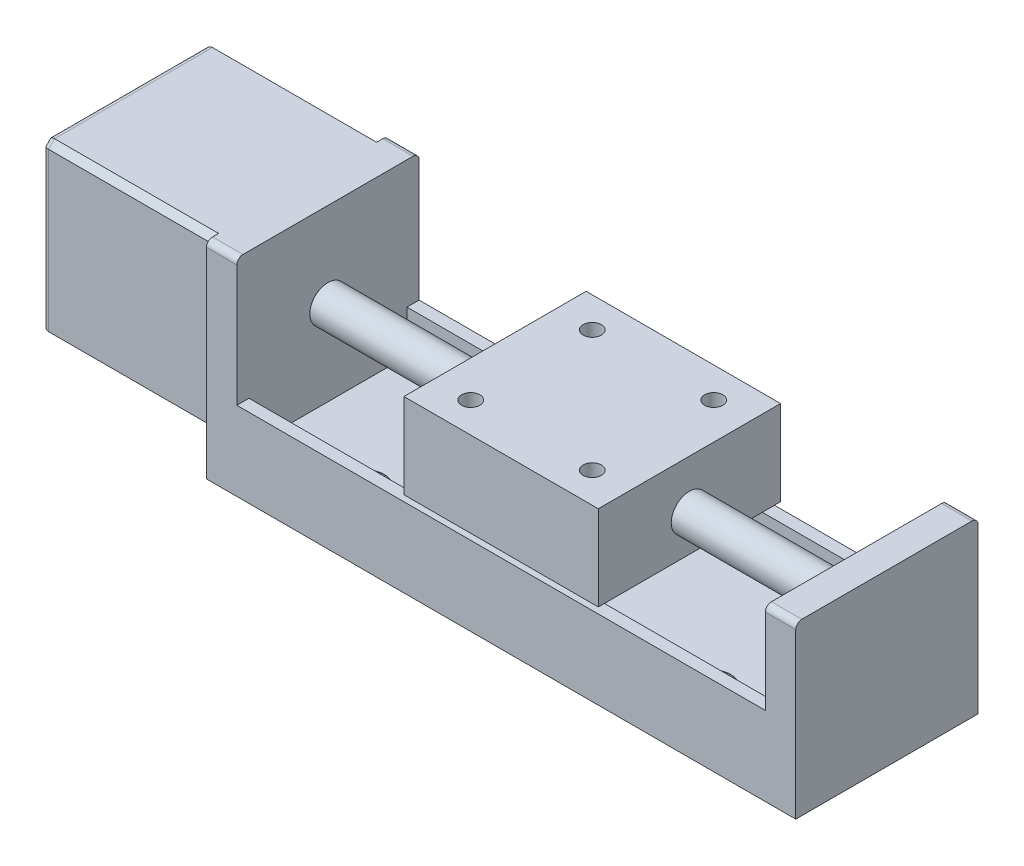
from build123d import *

# Parameters (mm, degrees)
BOSS_EXTRUDE1_DEPTH                          = 15
SKETCH2_W                                    = 87
SKETCH2_H                                    = 26
CUT_EXTRUDE1_DEPTH                           = 7
SKETCH3_R                                    = 3
BOSS_EXTRUDE2_DEPTH                          = 92
CUT_EXTRUDE2_DEPTH                           = 35
CHAMFER1_SIZE                                = 1
FILLET1_R                                    = 1
FILLET2_R                                    = 1
CBORE_FOR_M3_HEX_SOCKET_HEAD_CAP_SCR_2_COUNT = 2
CBORE_FOR_M3_HEX_SOCKET_HEAD_CAP_SCR_2_PITCH = 17
CBORE_FOR_M3_HEX_SOCKET_HEAD_CAP_SCR_3_COUNT = 2
CBORE_FOR_M3_HEX_SOCKET_HEAD_CAP_SCR_3_PITCH = 57
CBORE_FOR_M3_HEX_SOCKET_HEAD_CAP_SCR_4_COUNT = 2
CBORE_FOR_M3_HEX_SOCKET_HEAD_CAP_SCR_4_PITCH = 59.481089432
SKETCH7_W                                    = 32
SKETCH7_H                                    = 30
BOSS_EXTRUDE3_DEPTH                          = 14
SKETCH10_W                                   = 1.5
SKETCH10_H                                   = 6
HOLE1_AT_2_COUNT                             = 2
HOLE1_AT_2_PITCH                             = 20
HOLE1_AT_3_COUNT                             = 2
HOLE1_AT_3_PITCH                             = 28.284271247
HOLE1_AT_4_COUNT                             = 2
HOLE1_AT_4_PITCH                             = 20


with BuildPart() as part:
    # Sketch1 → Boss-Extrude1 (new body, symmetric)
    with BuildSketch(Plane.XY):
        Polygon((-78.5, 34), (-78.5, 6), (-48.5, 6), (-48.5, 0), (48.5, 0), (48.5, 28), (43.5, 28), (43.5, 13), (-43.5, 13), (-43.5, 34), align=None)
    extrude(amount=BOSS_EXTRUDE1_DEPTH, both=True)

    # Sketch2 → Cut-Extrude1 (cut)
    with BuildSketch(Plane(origin=(0, 13, 0), x_dir=(1, 0, 0), z_dir=(0, 1, 0))):
        Rectangle(SKETCH2_W, SKETCH2_H)
    extrude(amount=-CUT_EXTRUDE1_DEPTH, mode=Mode.SUBTRACT)

    # Sketch3 → Boss-Extrude2 (add)
    with BuildSketch(Plane(origin=(48.5, 0, 0), x_dir=(0, 0, -1), z_dir=(1, 0, 0))):
        with Locations((0, 20)):
            Circle(SKETCH3_R)
    extrude(amount=-BOSS_EXTRUDE2_DEPTH)

    # Sketch4 → Cut-Extrude2 (cut, through all)
    with BuildSketch(Plane(origin=(0, 34, 0), x_dir=(1, 0, 0), z_dir=(0, 1, 0))):
        Polygon((-48.5, -15), (-48.5, -14), (-76.5, -14), (-76.5, 14), (-48.5, 14), (-48.5, 15), (-78.5, 15), (-78.5, -15), align=None)
    extrude(amount=-CUT_EXTRUDE2_DEPTH, mode=Mode.SUBTRACT)

    # Chamfer1
    chamfer1_edges = [part.edges().sort_by_distance(p)[0] for p in [
        (-62.5, 6, -14),
        (-62.5, 6, 14),
        (-62.5, 34, 14),
        (-62.5, 34, -14),
    ]]
    chamfer(chamfer1_edges, length=CHAMFER1_SIZE)

    # Fillet1
    fillet1_edges = [part.edges().sort_by_distance(p)[0] for p in [
        (-76.5, 34, 0),
        (-76.5, 20, -14),
        (-76.5, 33.5, 13.5),
        (-76.5, 33.5, -13.5),
        (-76.5, 6.5, -13.5),
        (-76.5, 6.5, 13.5),
        (-76.5, 6, 0),
        (-76.5, 20, 14),
    ]]
    fillet(fillet1_edges, radius=FILLET1_R)

    # Fillet2
    fillet2_edges = [part.edges().sort_by_distance(p)[0] for p in [
        (-46, 34, -15),
        (46, 28, -15),
        (46, 28, 15),
        (-46, 34, 15),
    ]]
    fillet(fillet2_edges, radius=FILLET2_R)

    # Sketch6 → CBORE for M3 Hex Socket Head Cap Screw1 (revolve, cut)
    with BuildSketch(Plane(origin=(-28.5, 6, -8.006829487), x_dir=(0, 0, 1), z_dir=(1, 0, 0))):
        Polygon((0, 0), (0, 6), (1.7, 6), (1.7, 3.4), (3.25, 3.4), (3.25, 0.025), (3.275, 0), align=None)
    cbore_for_m3_hex_socket_head_cap_screw1 = revolve(axis=Axis((-28.5, 12.35, -8.006829487), (0, -1, 0)), mode=Mode.SUBTRACT)

    # CBORE for M3 Hex Socket Head Cap Scr 2: CBORE for M3 Hex Socket Head Cap Screw1 ×2
    with Locations(*[(0, 0, i * CBORE_FOR_M3_HEX_SOCKET_HEAD_CAP_SCR_2_PITCH) for i in range(1, CBORE_FOR_M3_HEX_SOCKET_HEAD_CAP_SCR_2_COUNT)]):
        add(cbore_for_m3_hex_socket_head_cap_screw1, mode=Mode.SUBTRACT)

    # CBORE for M3 Hex Socket Head Cap Scr 3: CBORE for M3 Hex Socket Head Cap Screw1 ×2
    with Locations(*[(i * CBORE_FOR_M3_HEX_SOCKET_HEAD_CAP_SCR_3_PITCH, 0, 0) for i in range(1, CBORE_FOR_M3_HEX_SOCKET_HEAD_CAP_SCR_3_COUNT)]):
        add(cbore_for_m3_hex_socket_head_cap_screw1, mode=Mode.SUBTRACT)

    # CBORE for M3 Hex Socket Head Cap Scr 4: CBORE for M3 Hex Socket Head Cap Screw1 ×2
    with Locations(*[Vector(0.958287761, 0, 0.285805122) * (i * CBORE_FOR_M3_HEX_SOCKET_HEAD_CAP_SCR_4_PITCH) for i in range(1, CBORE_FOR_M3_HEX_SOCKET_HEAD_CAP_SCR_4_COUNT)]):
        add(cbore_for_m3_hex_socket_head_cap_screw1, mode=Mode.SUBTRACT)


with BuildPart() as body_2:
    # Sketch7 → Boss-Extrude3 (new body)
    with BuildSketch(Plane(origin=(0, 28, 0), x_dir=(1, 0, 0), z_dir=(0, 1, 0))):
        Rectangle(SKETCH7_W, SKETCH7_H)
    extrude(amount=-BOSS_EXTRUDE3_DEPTH)

    # Sketch10 → Hole1 (revolve, cut)
    with BuildSketch(Plane(origin=(10, 28, -10), x_dir=(0, 0, 1), z_dir=(1, 0, 0))):
        with Locations((0.75, 3)):
            Rectangle(SKETCH10_W, SKETCH10_H)
    hole1 = revolve(axis=Axis((10, -82, -10), (0, 1, 0)), mode=Mode.SUBTRACT)

    # Hole1 at 2: Hole1 ×2
    with Locations(*[(0, 0, i * HOLE1_AT_2_PITCH) for i in range(1, HOLE1_AT_2_COUNT)]):
        add(hole1, mode=Mode.SUBTRACT)

    # Hole1 at 3: Hole1 ×2
    with Locations(*[Vector(-0.707106781, 0, 0.707106781) * (i * HOLE1_AT_3_PITCH) for i in range(1, HOLE1_AT_3_COUNT)]):
        add(hole1, mode=Mode.SUBTRACT)

    # Hole1 at 4: Hole1 ×2
    with Locations(*[(-i * HOLE1_AT_4_PITCH, 0, 0) for i in range(1, HOLE1_AT_4_COUNT)]):
        add(hole1, mode=Mode.SUBTRACT)


solid = Compound([part.part, body_2.part])
